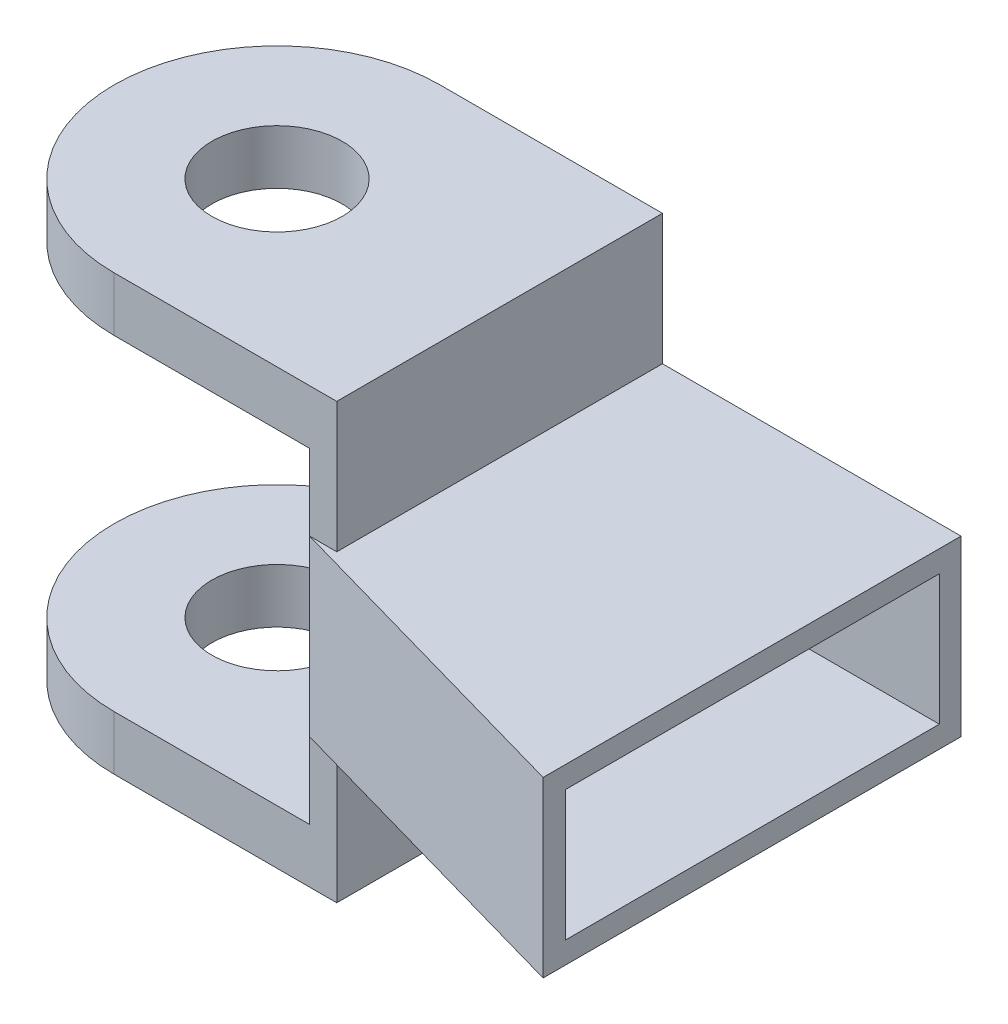
from build123d import *

# Parameters (mm, degrees)
BOSS_EXTRUDE1_DEPTH = 16
SHELL1_T            = -2
SKETCH2_R           = 6
BOSS_EXTRUDE2_DEPTH = 5
SKETCH4_W           = 30
SKETCH4_H           = 12
BOSS_EXTRUDE3_DEPTH = 2.5
SKETCH5_R           = 6
BOSS_EXTRUDE4_DEPTH = 5


with BuildPart() as part:
    # Sketch1 → Boss-Extrude1 (new body)
    with BuildSketch(Plane(origin=(0, 0, 0), x_dir=(1, 0, 0), z_dir=(0, 1, 0))):
        Polygon((-350, 31.008229654), (-320, 22.514402641), (-320, 61.008229654), (-350, 61.008229654), align=None)
    extrude(amount=BOSS_EXTRUDE1_DEPTH)

    # Shell1
    shell1_openings = [part.faces().sort_by_distance(p)[0] for p in [
        (-320, 8, -41.761316148),
    ]]
    offset(amount=SHELL1_T, openings=shell1_openings, kind=Kind.INTERSECTION)



with BuildPart() as body_2:
    # Sketch2 → Boss-Extrude2 (new body)
    with BuildSketch(Plane(origin=(0, 23, 0), x_dir=(1, 0, 0), z_dir=(0, 1, 0))):
        with BuildLine():
            Line((-350, 61.008229654), (-368, 61.008229654))
            ThreePointArc((-368, 61.008229654), (-383, 46.008229654), (-368, 31.008229654))
            Line((-368, 31.008229654), (-350, 31.008229654))
            Line((-350, 31.008229654), (-350, 61.008229654))
        make_face()
        with Locations((-368, 46.008229654)):
            Circle(SKETCH2_R, mode=Mode.SUBTRACT)
    extrude(amount=BOSS_EXTRUDE2_DEPTH)


with BuildPart() as part_1:
    add(part.part)

    add(body_2.part)  # Boss-Extrude3 merges body 2
    # Sketch4 → Boss-Extrude3 (add)
    with BuildSketch(Plane.ZY.offset(350)):
        with Locations((-46.008229654, 22)):
            Rectangle(SKETCH4_W, SKETCH4_H)
    boss_extrude3 = extrude(amount=-BOSS_EXTRUDE3_DEPTH)

    # Mirror14: Boss-Extrude3 across plane
    add(boss_extrude3.mirror(Plane(origin=(0, 8, 0), x_dir=(0, 0, 1), z_dir=(0, -1, 0))))

    # Sketch5 → Boss-Extrude4 (add)
    with BuildSketch(Plane.XZ.offset(12)):
        with BuildLine():
            Line((-350, -61.008229654), (-350, -31.008229654))
            Line((-350, -31.008229654), (-368, -31.008229654))
            ThreePointArc((-368, -31.008229654), (-383, -46.008229654), (-368, -61.008229654))
            Line((-368, -61.008229654), (-350, -61.008229654))
        make_face()
        with Locations((-368, -46.008229654)):
            Circle(SKETCH5_R, mode=Mode.SUBTRACT)
    extrude(amount=-BOSS_EXTRUDE4_DEPTH)


solid = part_1.part
